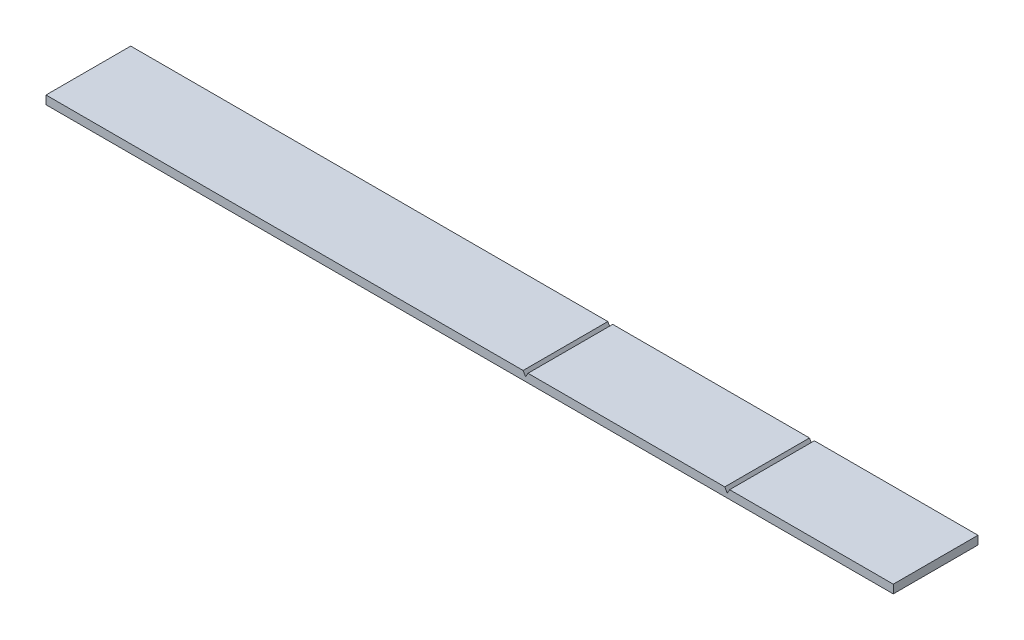
from build123d import *

# Parameters (mm, degrees)
BOSS_EXTRUDE1_DEPTH = 100


with BuildPart() as part:
    # Sketch1 → Boss-Extrude1 (new body)
    with BuildSketch(Plane.XY):
        Polygon((0, 0), (563.113248654, 0), (566, -5), (568.886751346, 0), (801.113248654, 0), (804, -5), (806.886751346, 0), (1000, 0), (1000, -10), (0, -10), align=None)
    extrude(amount=BOSS_EXTRUDE1_DEPTH)


solid = part.part
